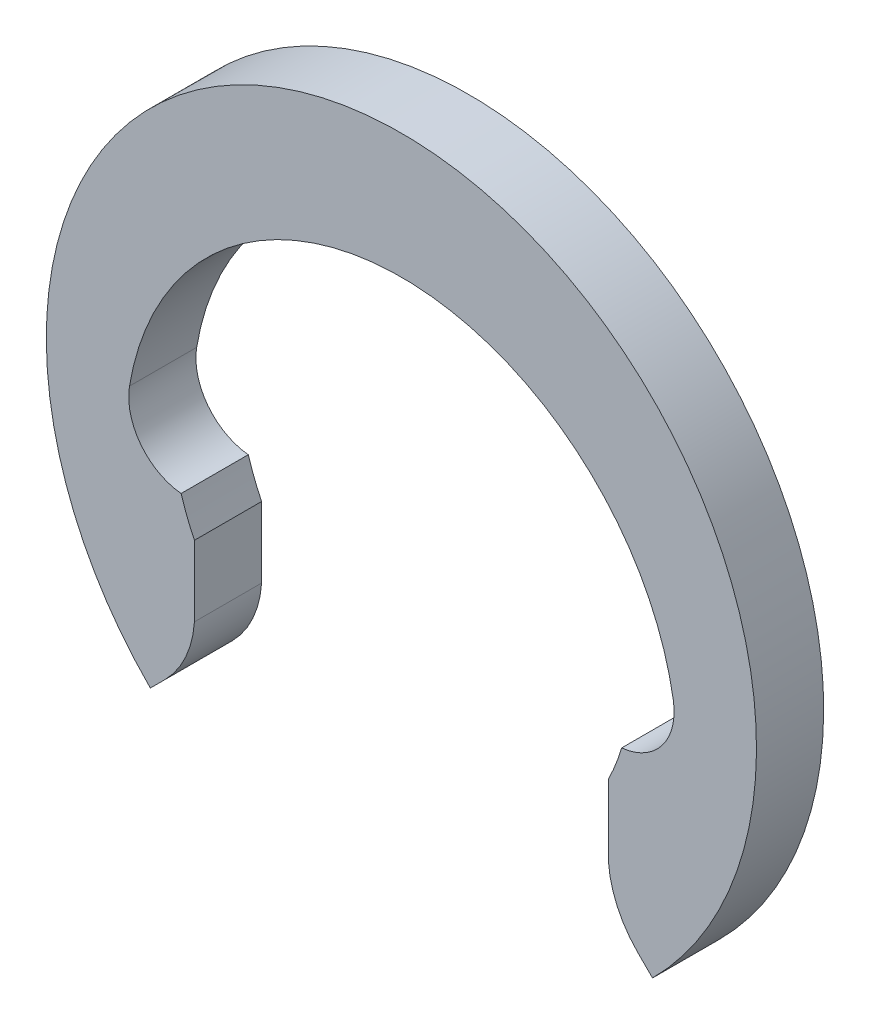
from build123d import *

# Parameters (mm, degrees)
BOSS_EXTRUDE1_DEPTH = 0.7


with BuildPart() as part:
    # Sketch2 → Boss-Extrude1 (new body)
    with BuildSketch(Plane.XY):
        with BuildLine():
            Line((-2.156675683, -1.78877445), (-2.156675683, -1.420873217))
            Line((-2.156675683, -1.420873217), (-2.156675683, -1.052971984))
            ThreePointArc((-2.156675683, -1.052971984), (-2.233146653, -0.879236046), (-2.295648057, -0.7))
            ThreePointArc((-2.295648057, -0.7), (-2.71665879, -0.466883635), (-2.833333333, 0))
            ThreePointArc((-2.833333333, 0), (0, 2.4), (2.833333333, 0))
            ThreePointArc((2.833333333, 0), (2.71665879, -0.466883635), (2.295648057, -0.7))
            ThreePointArc((2.295648057, -0.7), (2.233146653, -0.879236046), (2.156675683, -1.052971984))
            Line((2.156675683, -1.052971984), (2.156675683, -1.420873217))
            Line((2.156675683, -1.420873217), (2.156675683, -1.78877445))
            ThreePointArc((2.156675683, -1.78877445), (2.248723901, -2.15372226), (2.463088621, -2.463088621))
            Line((2.463088621, -2.463088621), (2.61629509, -2.61629509))
            ThreePointArc((2.61629509, -2.61629509), (0, 3.7), (-2.61629509, -2.61629509))
            Line((-2.61629509, -2.61629509), (-2.463088621, -2.463088621))
            ThreePointArc((-2.463088621, -2.463088621), (-2.248723901, -2.15372226), (-2.156675683, -1.78877445))
        make_face()
    extrude(amount=BOSS_EXTRUDE1_DEPTH)


solid = part.part
